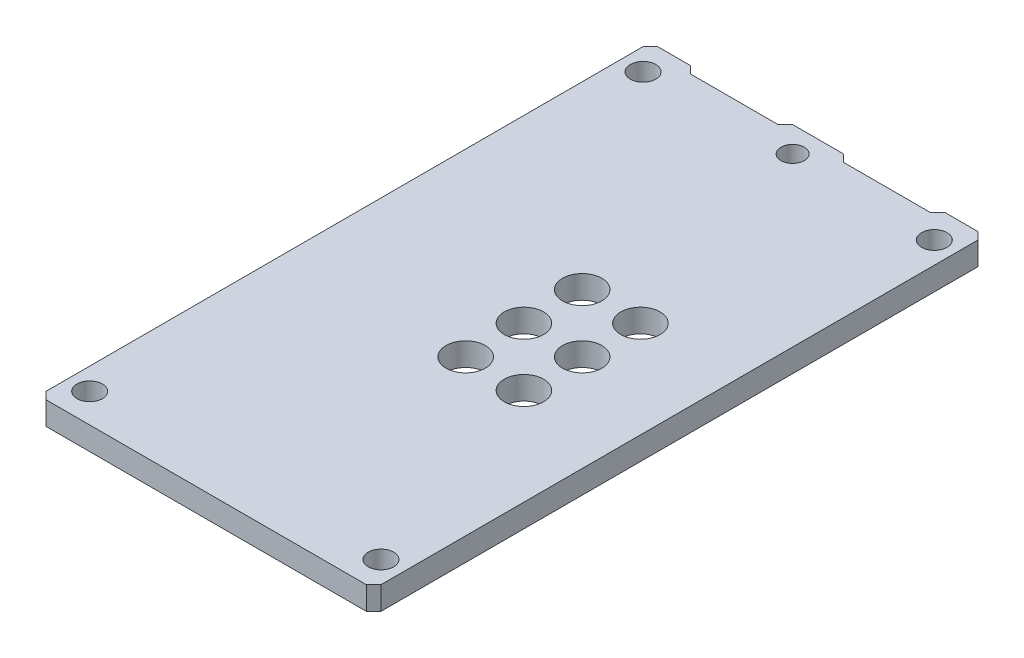
from build123d import *

# Parameters (mm, degrees)
SKETCH1_R           = 1.35
SKETCH1_R_2         = 0.875
SKETCH1_R_3         = 0.8001
BOSS_EXTRUDE1_DEPTH = 1.5875


with BuildPart() as part:
    # Sketch1 → Boss-Extrude1 (new body)
    with BuildSketch(Plane(origin=(0, 0, 0), x_dir=(1, 0, 0), z_dir=(0, 1, 0))):
        Polygon((22.5, 0), (23, 0.5), (23, 41.5), (22.5, 42), (20.25, 42), (19.75, 41.5), (13.75, 41.5), (13.25, 42), (9.75, 42), (9.25, 41.5), (3.25, 41.5), (2.75, 42), (0.5, 42), (0, 41.5), (0, 0.5), (0.5, 0), align=None)
        with Locations((12.36, 16.96)):
            Circle(SKETCH1_R, mode=Mode.SUBTRACT)
        with Locations((16.36, 16.96)):
            Circle(SKETCH1_R, mode=Mode.SUBTRACT)
        with Locations((12.36, 20.96)):
            Circle(SKETCH1_R, mode=Mode.SUBTRACT)
        with Locations((16.36, 20.96)):
            Circle(SKETCH1_R, mode=Mode.SUBTRACT)
        with Locations((12.36, 24.96)):
            Circle(SKETCH1_R, mode=Mode.SUBTRACT)
        with Locations((16.36, 24.96)):
            Circle(SKETCH1_R, mode=Mode.SUBTRACT)
        with Locations((21.5, 40)):
            Circle(SKETCH1_R_2, mode=Mode.SUBTRACT)
        with Locations((21.5, 2)):
            Circle(SKETCH1_R_2, mode=Mode.SUBTRACT)
        with Locations((1.5, 2)):
            Circle(SKETCH1_R_2, mode=Mode.SUBTRACT)
        with Locations((1.5, 40)):
            Circle(SKETCH1_R_2, mode=Mode.SUBTRACT)
        with Locations((11.5154, 40.2552)):
            Circle(SKETCH1_R_3, mode=Mode.SUBTRACT)
    extrude(amount=BOSS_EXTRUDE1_DEPTH)


solid = part.part
